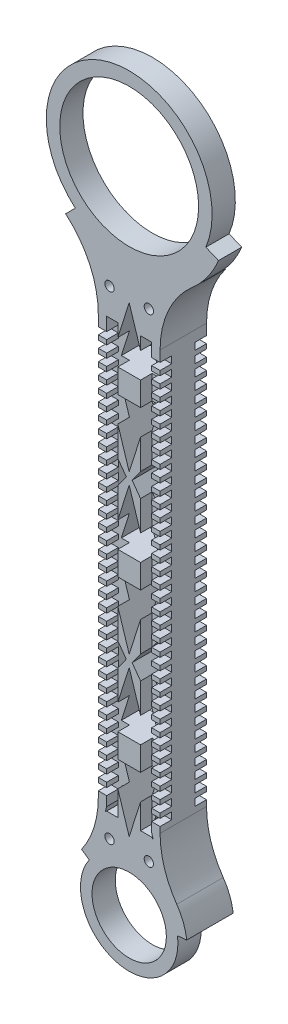
from build123d import *

# Parameters (mm, degrees)
SKETCH1_R               = 37.958395775
BOSS_EXTRUDE1_DEPTH     = 12.7
SKETCH2_R               = 20.32
CUT_EXTRUDE1_DEPTH      = 13.7
CUT_EXTRUDE2_DEPTH      = 13.7
BOSS_EXTRUDE2_DEPTH     = 12.7
CUT_EXTRUDE3_DEPTH      = 26.4
CUT_EXTRUDE4_DEPTH      = 26.4
SKETCH7_W               = 2.659588599
SKETCH7_H               = 144.218299066
BOSS_EXTRUDE3_DEPTH     = 25.4
SKETCH8_R               = 2.54
CUT_EXTRUDE5_DEPTH      = 26.4
SKETCH9_W               = 6.35
SKETCH9_H               = 3.81
CUT_EXTRUDE6_DEPTH      = 6.35
SKETCH10_W              = 6.088992538
SKETCH10_H              = 234.3333379
CUT_EXTRUDE8_DEPTH      = 6.35
MIRROR2_COPY_1_SKETCH_W = 6.088992538
MIRROR2_COPY_1_SKETCH_H = 234.3333379
MIRROR2_COPY_1_DEPTH    = 6.35


with BuildPart() as part:
    # Sketch1 → Boss-Extrude1 (new body)
    with BuildSketch(Plane.XY):
        with BuildLine():
            Line((41.912918035, -70.105620628), (48.8352458, -72.959893795))
            ThreePointArc((48.8352458, -72.959893795), (42.837606672, -83.731427434), (34.5064888, -92.819336271))
            ThreePointArc((34.5064888, -92.819336271), (21.504350582, -110.13005032), (16.891, -131.282672274))
            Line((16.891, -131.282672274), (16.891, -360.114950628))
            ThreePointArc((16.891, -360.114950628), (19.226049546, -375.339554974), (26.016534546, -389.164544931))
            ThreePointArc((26.016534546, -389.164544931), (0, -439.01304823), (-26.016534546, -389.164544931))
            ThreePointArc((-26.016534546, -389.164544931), (-19.226049546, -375.339554974), (-16.891, -360.114950628))
            Line((-16.891, -360.114950628), (-16.891, -131.282672274))
            ThreePointArc((-16.891, -131.282672274), (-21.504350582, -110.13005032), (-34.5064888, -92.819336271))
            ThreePointArc((-34.5064888, -92.819336271), (-34.628775378, -92.713505712), (-34.750737377, -92.607301263))
            Line((-34.750737377, -92.607301263), (-29.442085085, -87.29864897))
            ThreePointArc((-29.442085085, -87.29864897), (-10.619815183, -8.74906524), (41.912918035, -70.105620628))
        make_face()
        with Locations((0, -52.823729134)):
            Circle(SKETCH1_R, mode=Mode.SUBTRACT)
    extrude(amount=BOSS_EXTRUDE1_DEPTH)

    # Sketch2 → Cut-Extrude1 (cut, through all)
    with BuildSketch(Plane.XY.offset(12.7)):
        with Locations((0, -407.299625141)):
            Circle(SKETCH2_R)
    extrude(amount=-CUT_EXTRUDE1_DEPTH, mode=Mode.SUBTRACT)

    # Sketch3 → Cut-Extrude2 (cut, through all)
    with BuildSketch(Plane.XY.offset(12.7)):
        with BuildLine():
            Line((31.466672854, -403.351245283), (26.409345327, -403.852060083))
            ThreePointArc((26.409345327, -403.852060083), (-6.317130801, -433.173030094), (-21.849088001, -392.069504361))
            Line((-21.849088001, -392.069504361), (-26.016534546, -389.164544931))
            ThreePointArc((-26.016534546, -389.164544931), (-7.598790602, -438.089227045), (31.466672854, -403.351245283))
        make_face()
    extrude(amount=-CUT_EXTRUDE2_DEPTH, mode=Mode.SUBTRACT)

    # Sketch4 → Boss-Extrude2 (add)
    with BuildSketch(Plane(origin=(0, 0, 0), x_dir=(-1, 0, 0), z_dir=(0, 0, -1))):
        with BuildLine():
            Line((-31.466672854, -403.351245283), (-27.729137778, -403.721364258))
            ThreePointArc((-27.729137778, -403.721364258), (-6.651587991, -380.143310772), (22.936592081, -391.311448991))
            Line((22.936592081, -391.311448991), (26.016534546, -389.164544931))
            ThreePointArc((26.016534546, -389.164544931), (19.226049546, -375.339554974), (16.891, -360.114950628))
            Line((16.891, -360.114950628), (16.891, -131.282672274))
            ThreePointArc((16.891, -131.282672274), (19.601252021, -114.911473805), (27.442816508, -100.287128633))
            ThreePointArc((27.442816508, -100.287128633), (0, -107.649657944), (-27.442816508, -100.287128633))
            ThreePointArc((-27.442816508, -100.287128633), (-19.601252021, -114.911473805), (-16.891, -131.282672274))
            Line((-16.891, -131.282672274), (-16.891, -360.114950628))
            ThreePointArc((-16.891, -360.114950628), (-19.226049546, -375.339554974), (-26.016534546, -389.164544931))
            ThreePointArc((-26.016534546, -389.164544931), (-29.603976084, -395.926595464), (-31.466672854, -403.351245283))
        make_face()
    extrude(amount=BOSS_EXTRUDE2_DEPTH)

    # Sketch5 → Cut-Extrude3 (cut, through all)
    with BuildSketch(Plane(origin=(0, 0, -12.7), x_dir=(-1, 0, 0), z_dir=(0, 0, -1))):
        Polygon((0, -117.328719159), (-10.643008417, -150.850603507), (10.643008417, -150.850603507), align=None)
        Polygon((-10.643008417, -163.910204627), (10.643008417, -163.910204627), (0, -197.432088975), align=None)
        Polygon((0, -203.688719159), (-10.643008417, -237.210603507), (10.643008417, -237.210603507), align=None)
        Polygon((-10.643008417, -250.270204627), (10.643008417, -250.270204627), (0, -283.792088975), align=None)
        Polygon((0, -290.048719159), (-10.643008417, -323.570603507), (10.643008417, -323.570603507), align=None)
        Polygon((-10.643008417, -336.630204627), (10.643008417, -336.630204627), (0, -370.152088975), align=None)
    extrude(amount=-CUT_EXTRUDE3_DEPTH, mode=Mode.SUBTRACT)

    # Sketch6 → Cut-Extrude4 (cut, through all)
    with BuildSketch(Plane(origin=(0, 0, -12.7), x_dir=(-1, 0, 0), z_dir=(0, 0, -1))):
        Polygon((-1.594091403, -200.550582459), (-14.024025504, -183.348211014), (-14.024025504, -217.752953904), align=None)
        Polygon((1.594091403, -200.550582459), (14.024025504, -217.752953904), (14.024025504, -183.348211014), align=None)
        Polygon((14.024025504, -304.13259712), (14.024025504, -269.727854229), (1.594091403, -286.930225675), align=None)
        Polygon((-1.594091403, -286.930225675), (-14.024025504, -269.727854229), (-14.024025504, -304.13259712), align=None)
        with BuildLine():
            Line((-10.156050114, -354.191909444), (-7.685481775, -361.159563066))
            ThreePointArc((-7.685481775, -361.159563066), (-10.561707814, -362.817725068), (-13.091927145, -364.967182577))
            Line((-13.091927145, -364.967182577), (-10.156050114, -354.191909444))
        make_face()
        with BuildLine():
            Line((13.091927145, -364.967182577), (10.156050114, -354.191909444))
            Line((10.156050114, -354.191909444), (7.685481775, -361.159563066))
            ThreePointArc((7.685481775, -361.159563066), (10.561707814, -362.817725068), (13.091927145, -364.967182577))
        make_face()
    extrude(amount=-CUT_EXTRUDE4_DEPTH, mode=Mode.SUBTRACT)

    # Sketch7 → Boss-Extrude3 (add)
    with BuildSketch(Plane(origin=(0, 0, -12.7), x_dir=(-1, 0, 0), z_dir=(0, 0, -1))):
        with Locations((-13.619905356, -245.566634858)):
            Rectangle(SKETCH7_W, SKETCH7_H)
        with Locations((13.619905356, -245.566634858)):
            Rectangle(SKETCH7_W, SKETCH7_H)
    extrude(amount=-BOSS_EXTRUDE3_DEPTH)

    # Sketch8 → Cut-Extrude5 (cut, through all)
    with BuildSketch(Plane(origin=(0, 0, -12.7), x_dir=(-1, 0, 0), z_dir=(0, 0, -1))):
        with Locations((-10.756405179, -114.872047193)):
            Circle(SKETCH8_R)
        with Locations((10.756405179, -114.872047193)):
            Circle(SKETCH8_R)
        with Locations((-10.756405179, -376.525575709)):
            Circle(SKETCH8_R)
        with Locations((10.756405179, -376.525575709)):
            Circle(SKETCH8_R)
    extrude(amount=-CUT_EXTRUDE5_DEPTH, mode=Mode.SUBTRACT)

    # Sketch9 → Cut-Extrude6 (cut)
    with BuildSketch(Plane(origin=(16.891, 0, 0), x_dir=(0, 0, -1), z_dir=(1, 0, 0))):
        with Locations((9.525, -354.975900097)):
            Rectangle(SKETCH9_W, SKETCH9_H)
        with Locations((9.525, -348.625900097)):
            Rectangle(SKETCH9_W, SKETCH9_H)
        with Locations((9.525, -342.275900097)):
            Rectangle(SKETCH9_W, SKETCH9_H)
        with Locations((9.525, -335.925900097)):
            Rectangle(SKETCH9_W, SKETCH9_H)
        with Locations((9.525, -329.575900097)):
            Rectangle(SKETCH9_W, SKETCH9_H)
        with Locations((9.525, -323.225900097)):
            Rectangle(SKETCH9_W, SKETCH9_H)
        with Locations((9.525, -316.875900097)):
            Rectangle(SKETCH9_W, SKETCH9_H)
        with Locations((9.525, -310.525900097)):
            Rectangle(SKETCH9_W, SKETCH9_H)
        with Locations((9.525, -304.175900097)):
            Rectangle(SKETCH9_W, SKETCH9_H)
        with Locations((9.525, -297.825900097)):
            Rectangle(SKETCH9_W, SKETCH9_H)
        with Locations((9.525, -291.475900097)):
            Rectangle(SKETCH9_W, SKETCH9_H)
        with Locations((9.525, -285.125900097)):
            Rectangle(SKETCH9_W, SKETCH9_H)
        with Locations((9.525, -278.775900097)):
            Rectangle(SKETCH9_W, SKETCH9_H)
        with Locations((9.525, -272.425900097)):
            Rectangle(SKETCH9_W, SKETCH9_H)
        with Locations((9.525, -266.075900097)):
            Rectangle(SKETCH9_W, SKETCH9_H)
        with Locations((9.525, -259.725900097)):
            Rectangle(SKETCH9_W, SKETCH9_H)
        with Locations((9.525, -253.375900097)):
            Rectangle(SKETCH9_W, SKETCH9_H)
        with Locations((9.525, -247.025900097)):
            Rectangle(SKETCH9_W, SKETCH9_H)
        with Locations((9.525, -240.675900097)):
            Rectangle(SKETCH9_W, SKETCH9_H)
        with Locations((9.525, -234.325900097)):
            Rectangle(SKETCH9_W, SKETCH9_H)
        with Locations((9.525, -227.975900097)):
            Rectangle(SKETCH9_W, SKETCH9_H)
        with Locations((9.525, -221.625900097)):
            Rectangle(SKETCH9_W, SKETCH9_H)
        with Locations((9.525, -215.275900097)):
            Rectangle(SKETCH9_W, SKETCH9_H)
        with Locations((9.525, -208.925900097)):
            Rectangle(SKETCH9_W, SKETCH9_H)
        with Locations((9.525, -202.575900097)):
            Rectangle(SKETCH9_W, SKETCH9_H)
        with Locations((9.525, -196.225900097)):
            Rectangle(SKETCH9_W, SKETCH9_H)
        with Locations((9.525, -189.875900097)):
            Rectangle(SKETCH9_W, SKETCH9_H)
        with Locations((9.525, -183.525900097)):
            Rectangle(SKETCH9_W, SKETCH9_H)
        with Locations((9.525, -177.175900097)):
            Rectangle(SKETCH9_W, SKETCH9_H)
        with Locations((9.525, -170.825900097)):
            Rectangle(SKETCH9_W, SKETCH9_H)
        with Locations((9.525, -164.475900097)):
            Rectangle(SKETCH9_W, SKETCH9_H)
        with Locations((9.525, -158.125900097)):
            Rectangle(SKETCH9_W, SKETCH9_H)
        with Locations((9.525, -151.775900097)):
            Rectangle(SKETCH9_W, SKETCH9_H)
        with Locations((9.525, -145.425900097)):
            Rectangle(SKETCH9_W, SKETCH9_H)
        with Locations((9.525, -139.075900097)):
            Rectangle(SKETCH9_W, SKETCH9_H)
        with Locations((-9.525, -139.075900097)):
            Rectangle(SKETCH9_W, SKETCH9_H)
        with Locations((-9.525, -145.425900097)):
            Rectangle(SKETCH9_W, SKETCH9_H)
        with Locations((-9.525, -151.775900097)):
            Rectangle(SKETCH9_W, SKETCH9_H)
        with Locations((-9.525, -158.125900097)):
            Rectangle(SKETCH9_W, SKETCH9_H)
        with Locations((-9.525, -164.475900097)):
            Rectangle(SKETCH9_W, SKETCH9_H)
        with Locations((-9.525, -170.825900097)):
            Rectangle(SKETCH9_W, SKETCH9_H)
        with Locations((-9.525, -177.175900097)):
            Rectangle(SKETCH9_W, SKETCH9_H)
        with Locations((-9.525, -183.525900097)):
            Rectangle(SKETCH9_W, SKETCH9_H)
        with Locations((-9.525, -189.875900097)):
            Rectangle(SKETCH9_W, SKETCH9_H)
        with Locations((-9.525, -196.225900097)):
            Rectangle(SKETCH9_W, SKETCH9_H)
        with Locations((-9.525, -202.575900097)):
            Rectangle(SKETCH9_W, SKETCH9_H)
        with Locations((-9.525, -208.925900097)):
            Rectangle(SKETCH9_W, SKETCH9_H)
        with Locations((-9.525, -215.275900097)):
            Rectangle(SKETCH9_W, SKETCH9_H)
        with Locations((-9.525, -221.625900097)):
            Rectangle(SKETCH9_W, SKETCH9_H)
        with Locations((-9.525, -227.975900097)):
            Rectangle(SKETCH9_W, SKETCH9_H)
        with Locations((-9.525, -234.325900097)):
            Rectangle(SKETCH9_W, SKETCH9_H)
        with Locations((-9.525, -240.675900097)):
            Rectangle(SKETCH9_W, SKETCH9_H)
        with Locations((-9.525, -247.025900097)):
            Rectangle(SKETCH9_W, SKETCH9_H)
        with Locations((-9.525, -253.375900097)):
            Rectangle(SKETCH9_W, SKETCH9_H)
        with Locations((-9.525, -259.725900097)):
            Rectangle(SKETCH9_W, SKETCH9_H)
        with Locations((-9.525, -266.075900097)):
            Rectangle(SKETCH9_W, SKETCH9_H)
        with Locations((-9.525, -272.425900097)):
            Rectangle(SKETCH9_W, SKETCH9_H)
        with Locations((-9.525, -278.775900097)):
            Rectangle(SKETCH9_W, SKETCH9_H)
        with Locations((-9.525, -285.125900097)):
            Rectangle(SKETCH9_W, SKETCH9_H)
        with Locations((-9.525, -291.475900097)):
            Rectangle(SKETCH9_W, SKETCH9_H)
        with Locations((-9.525, -297.825900097)):
            Rectangle(SKETCH9_W, SKETCH9_H)
        with Locations((-9.525, -304.175900097)):
            Rectangle(SKETCH9_W, SKETCH9_H)
        with Locations((-9.525, -310.525900097)):
            Rectangle(SKETCH9_W, SKETCH9_H)
        with Locations((-9.525, -316.875900097)):
            Rectangle(SKETCH9_W, SKETCH9_H)
        with Locations((-9.525, -323.225900097)):
            Rectangle(SKETCH9_W, SKETCH9_H)
        with Locations((-9.525, -329.575900097)):
            Rectangle(SKETCH9_W, SKETCH9_H)
        with Locations((-9.525, -335.925900097)):
            Rectangle(SKETCH9_W, SKETCH9_H)
        with Locations((-9.525, -342.275900097)):
            Rectangle(SKETCH9_W, SKETCH9_H)
        with Locations((-9.525, -348.625900097)):
            Rectangle(SKETCH9_W, SKETCH9_H)
        with Locations((-9.525, -354.975900097)):
            Rectangle(SKETCH9_W, SKETCH9_H)
    cut_extrude6 = extrude(amount=-CUT_EXTRUDE6_DEPTH, mode=Mode.SUBTRACT)

    # Sketch10 → Cut-Extrude8 (cut)
    with BuildSketch(Plane(origin=(0, 0, -12.7), x_dir=(-1, 0, 0), z_dir=(0, 0, -1))):
        with Locations((-9.259438073, -247.038831108)):
            Rectangle(SKETCH10_W, SKETCH10_H)
    cut_extrude8 = extrude(amount=-CUT_EXTRUDE8_DEPTH, mode=Mode.SUBTRACT)

    # Mirror1: Cut-Extrude8 across plane
    add(cut_extrude8.mirror(Plane.XY), mode=Mode.SUBTRACT)

    # Mirror2: Cut-Extrude8 across plane
    add(cut_extrude8.mirror(Plane(origin=(0, 0, 0), x_dir=(0, 0, 1), z_dir=(1, 0, 0))), mode=Mode.SUBTRACT)

    # Mirror2 copy 1 sketch → Mirror2 copy 1 (cut)
    with BuildSketch(Plane.XY.offset(12.7)):
        with Locations((-9.259438073, -247.038831108)):
            Rectangle(MIRROR2_COPY_1_SKETCH_W, MIRROR2_COPY_1_SKETCH_H)
    extrude(amount=-MIRROR2_COPY_1_DEPTH, mode=Mode.SUBTRACT)

    # Mirror3: Cut-Extrude6 across plane
    add(cut_extrude6.mirror(Plane(origin=(0, 0, 0), x_dir=(0, 0, 1), z_dir=(1, 0, 0))), mode=Mode.SUBTRACT)


solid = part.part
